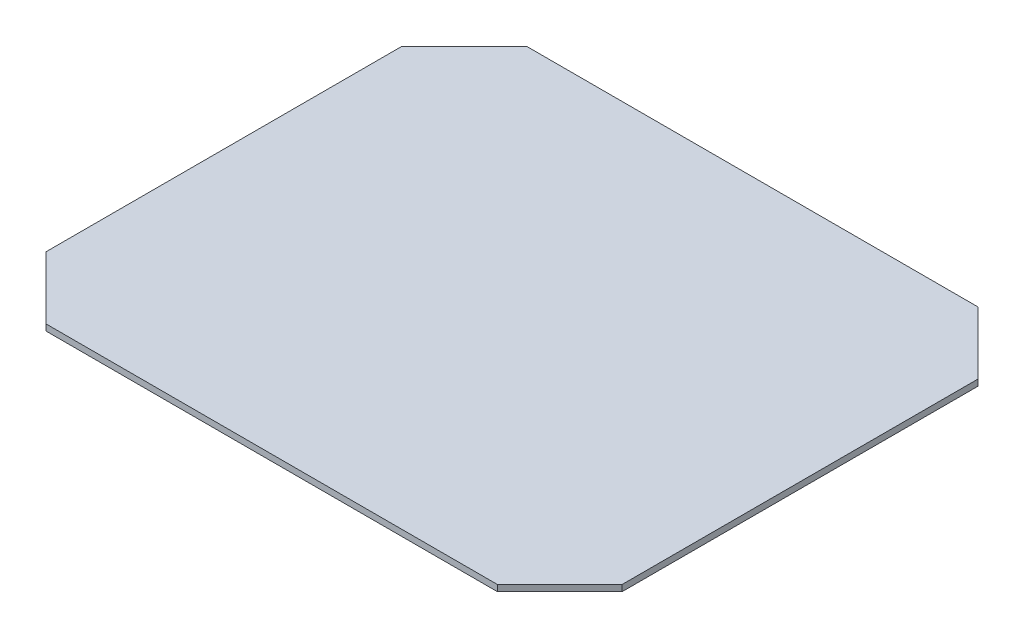
from build123d import *

# Parameters (mm, degrees)
BOSS_EXTRUDE1_DEPTH = 6.35


with BuildPart() as part:
    # Sketch1 → Boss-Extrude1 (new body, symmetric)
    with BuildSketch(Plane(origin=(0, 0, 0), x_dir=(1, 0, 0), z_dir=(0, 1, 0))):
        Polygon((-459.105, 488.95), (-586.105, 361.95), (-586.105, -361.95), (-459.105, -488.95), (459.105, -488.95), (586.105, -361.95), (586.105, 361.95), (459.105, 488.95), align=None)
    extrude(amount=BOSS_EXTRUDE1_DEPTH, both=True)


solid = part.part
